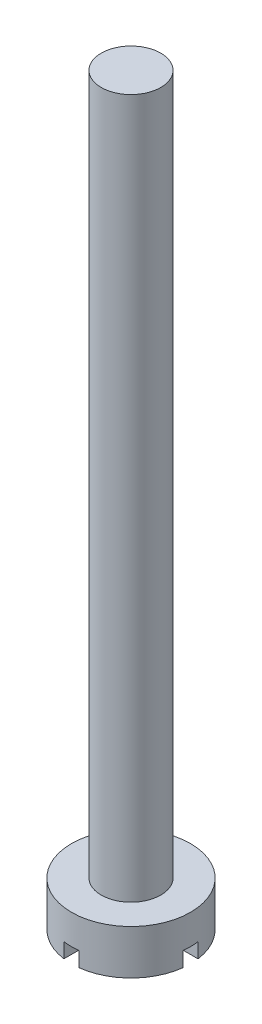
from build123d import *

# Parameters (mm, degrees)
SKETCH1_R           = 4
SKETCH1_R_2         = 2
BOSS_EXTRUDE1_DEPTH = 3
SKETCH1_3_R         = 2
BOSS_EXTRUDE2_DEPTH = 50
CUT_EXTRUDE1_DEPTH  = 1


with BuildPart() as part:
    # Sketch1 → Boss-Extrude1 (new body)
    with BuildSketch(Plane(origin=(0, 0, 0), x_dir=(1, 0, 0), z_dir=(0, 1, 0))):
        Circle(SKETCH1_R)
        Circle(SKETCH1_R_2, mode=Mode.SUBTRACT)
    extrude(amount=BOSS_EXTRUDE1_DEPTH)

    # Sketch1_3 → Boss-Extrude2 (add)
    with BuildSketch(Plane(origin=(0, 0, 0), x_dir=(1, 0, 0), z_dir=(0, 1, 0))):
        Circle(SKETCH1_3_R)
    extrude(amount=BOSS_EXTRUDE2_DEPTH)

    # Sketch2 → Cut-Extrude1 (cut)
    with BuildSketch(Plane(origin=(0, 0, 0), x_dir=(-1, 0, 0), z_dir=(0, -1, 0))):
        with BuildLine():
            Line((0.548123782, 4.189984677), (-0.463797046, 4.189984677))
            Line((-0.463797046, 4.189984677), (-0.463797046, 0.542853361))
            Line((-0.463797046, 0.542853361), (-3.962992585, 0.542853361))
            ThreePointArc((-3.962992585, 0.542853361), (-3.999827093, 0.037191701), (-3.972401756, -0.469067467))
            Line((-3.972401756, -0.469067467), (-0.463797046, -0.469067467))
            Line((-0.463797046, -0.469067467), (-0.463797046, -4.337556464))
            Line((-0.463797046, -4.337556464), (0.548123782, -4.337556464))
            Line((0.548123782, -4.337556464), (0.548123782, -0.469067467))
            Line((0.548123782, -0.469067467), (3.972401756, -0.469067467))
            ThreePointArc((3.972401756, -0.469067467), (3.999827093, 0.037191701), (3.962992585, 0.542853361))
            Line((3.962992585, 0.542853361), (0.548123782, 0.542853361))
            Line((0.548123782, 0.542853361), (0.548123782, 4.189984677))
        make_face()
    extrude(amount=-CUT_EXTRUDE1_DEPTH, mode=Mode.SUBTRACT)


solid = part.part
